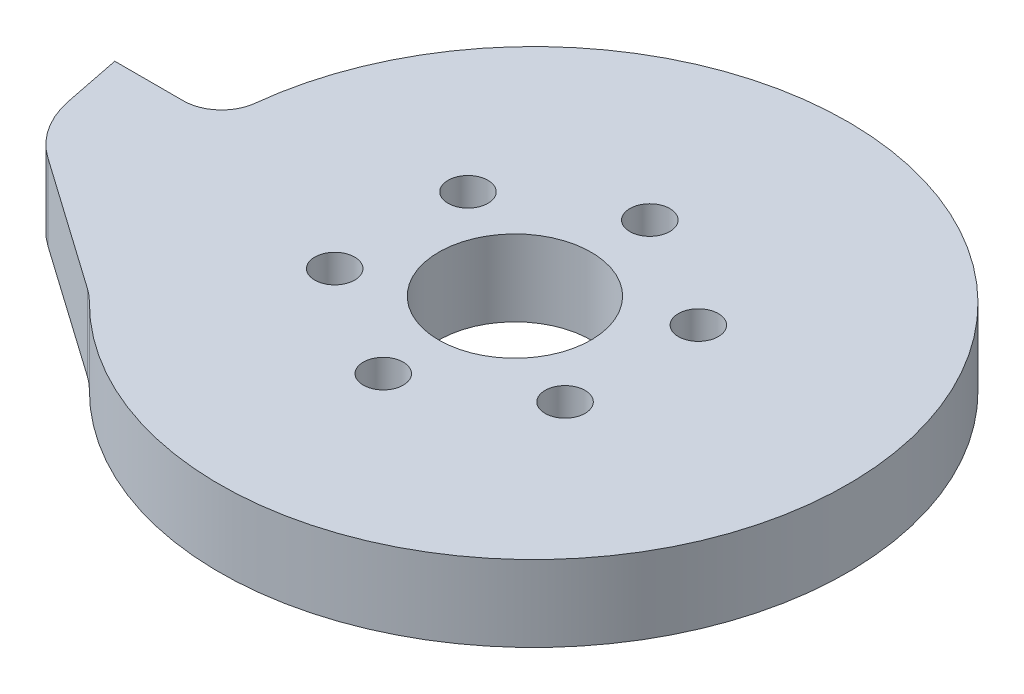
from build123d import *

# Parameters (mm, degrees)
SKETCH1_R           = 8
BOSS_EXTRUDE1_DEPTH = 8
FILLET1_R           = 4
FILLET2_R           = 10
SKETCH2_R           = 2.1
CUT_EXTRUDE1_DEPTH  = 9


with BuildPart() as part:
    # Sketch1 → Boss-Extrude1 (new body)
    with BuildSketch(Plane(origin=(0, 0, 0), x_dir=(1, 0, 0), z_dir=(0, 1, 0))):
        with BuildLine():
            Line((-33, 0), (-44, 0))
            Line((-44, 0), (-42, -10))
            Line((-42, -10), (-24, -22.649503306))
            ThreePointArc((-24, -22.649503306), (30.66757245, 12.186057607), (-33, 0))
        make_face()
        with Locations((-1.62, -0.35)):
            Circle(SKETCH1_R, mode=Mode.SUBTRACT)
    extrude(amount=BOSS_EXTRUDE1_DEPTH)

    # Fillet1
    fillet1_edges = [part.edges().sort_by_distance(p)[0] for p in [
        (-33, 4, 0),
    ]]
    fillet(fillet1_edges, radius=FILLET1_R)

    # Fillet2
    fillet2_edges = [part.edges().sort_by_distance(p)[0] for p in [
        (-24, 4, 22.649503306),
        (-42, 4, 10),
    ]]
    fillet(fillet2_edges, radius=FILLET2_R)

    # Sketch2 → Cut-Extrude1 (cut, through all)
    with BuildSketch(Plane(origin=(0, 8, 0), x_dir=(1, 0, 0), z_dir=(0, 1, 0))):
        with Locations((-1.452372624, 13.648996431)):
            Circle(SKETCH2_R)
        with Locations((10.650920222, 6.644137969)):
            Circle(SKETCH2_R)
        with Locations((10.636181267, -7.340050335)):
            Circle(SKETCH2_R)
        with Locations((-1.481850533, -14.319380179)):
            Circle(SKETCH2_R)
        with Locations((-13.585143379, -7.314521718)):
            Circle(SKETCH2_R)
        with Locations((-13.570404425, 6.669666587)):
            Circle(SKETCH2_R)
    extrude(amount=-CUT_EXTRUDE1_DEPTH, mode=Mode.SUBTRACT)


solid = part.part
